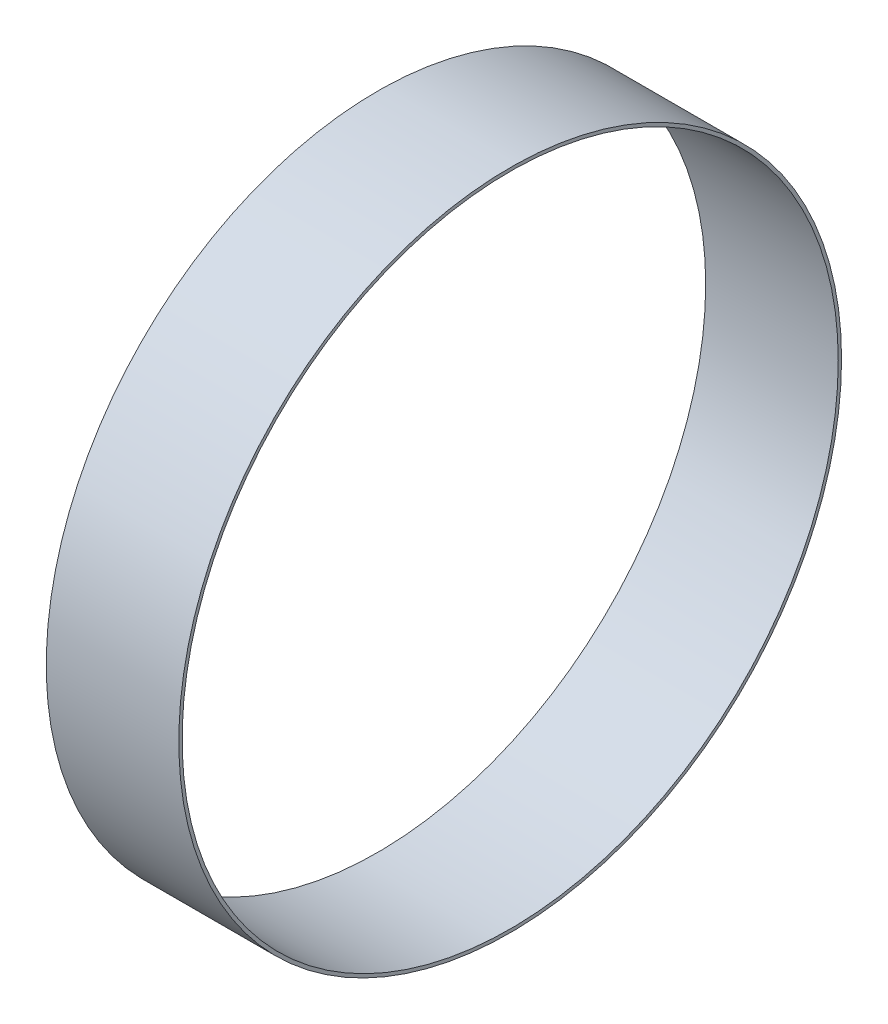
from build123d import *

# Parameters (mm, degrees)
SKETCH1_R           = 50
SKETCH1_R_2         = 49.5
BOSS_EXTRUDE1_DEPTH = 20


with BuildPart() as part:
    # Sketch1 → Boss-Extrude1 (new body)
    with BuildSketch(Plane(origin=(0, 0, 0), x_dir=(0, 0, -1), z_dir=(1, 0, 0))):
        Circle(SKETCH1_R)
        Circle(SKETCH1_R_2, mode=Mode.SUBTRACT)
    extrude(amount=BOSS_EXTRUDE1_DEPTH)


solid = part.part
